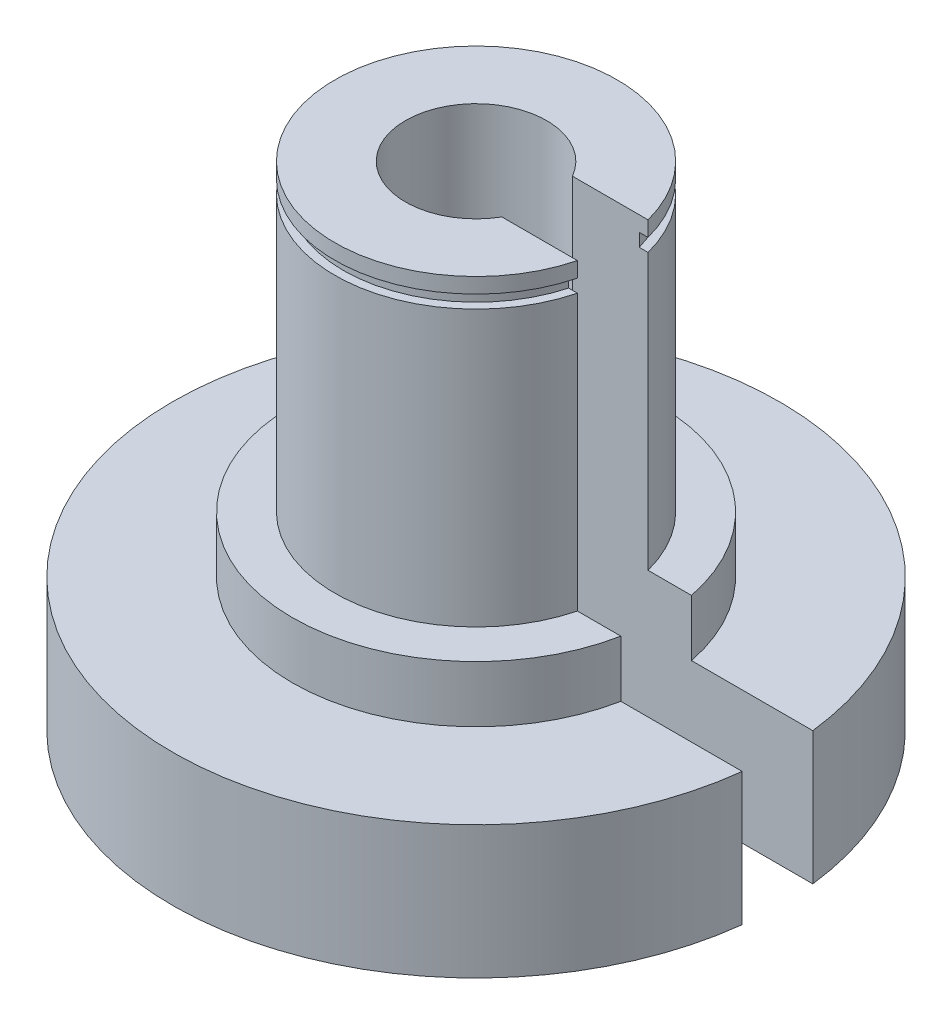
from build123d import *

# Parameters (mm, degrees)
SKETCH1_R           = 27.305
SKETCH1_R_2         = 4.5466
BOSS_EXTRUDE1_DEPTH = 57.658
SKETCH2_R           = 6.35
CUT_EXTRUDE1_DEPTH  = 44.45
SKETCH3_OUTSIDE_W   = 75.886
SKETCH3_OUTSIDE_H   = 75.886
SKETCH3_OUTSIDE_R   = 12.7
CUT_EXTRUDE2_DEPTH  = 44.45
SKETCH10_W          = 30.679481275
SKETCH10_H          = 6.35
CUT_EXTRUDE7_DEPTH  = 6.35
SKETCH13_OUTSIDE_W  = 75.886
SKETCH13_OUTSIDE_H  = 75.886
SKETCH13_OUTSIDE_R  = 11.938
CUT_EXTRUDE9_DEPTH  = 1.1684
SKETCH16_R          = 46.08237905
CUT_EXTRUDE11_DEPTH = 59.784814187
BOSS_EXTRUDE4_START = 3.81
SKETCH18_R          = 16.51
SKETCH18_R_2        = 12.7
BOSS_EXTRUDE4_DEPTH = 3.81
SKETCH19_OUTSIDE_W  = 74.42
SKETCH19_OUTSIDE_H  = 74.42
SKETCH19_OUTSIDE_R  = 16.51
CUT_EXTRUDE12_DEPTH = 1.27
SKETCH10_2_W        = 30.679481275
SKETCH10_2_H        = 6.35
CUT_EXTRUDE13_DEPTH = 59.784814187


with BuildPart() as part:
    # Sketch1 → Boss-Extrude1 (new body)
    with BuildSketch(Plane(origin=(0, 0, 0), x_dir=(1, 0, 0), z_dir=(0, 1, 0))):
        Circle(SKETCH1_R)
        Circle(SKETCH1_R_2, mode=Mode.SUBTRACT)
    extrude(amount=BOSS_EXTRUDE1_DEPTH)

    # Sketch2 → Cut-Extrude1 (cut)
    with BuildSketch(Plane(origin=(0, 57.658, 0), x_dir=(1, 0, 0), z_dir=(0, 1, 0))):
        Circle(SKETCH2_R)
    extrude(amount=-CUT_EXTRUDE1_DEPTH, mode=Mode.SUBTRACT)

    # Sketch3 outside → Cut-Extrude2 (cut)
    with BuildSketch(Plane(origin=(0, 57.658, 0), x_dir=(1, 0, 0), z_dir=(0, 1, 0))):
        Rectangle(SKETCH3_OUTSIDE_W, SKETCH3_OUTSIDE_H)
        Circle(SKETCH3_OUTSIDE_R, mode=Mode.SUBTRACT)
    extrude(amount=-CUT_EXTRUDE2_DEPTH, mode=Mode.SUBTRACT)

    # Sketch10 → Cut-Extrude7 (cut)
    with BuildSketch(Plane.XZ):
        with Locations((17.839550223, 0)):
            Rectangle(SKETCH10_W, SKETCH10_H)
    extrude(amount=-CUT_EXTRUDE7_DEPTH, mode=Mode.SUBTRACT)

    # Sketch13 outside → Cut-Extrude9 (cut)
    with BuildSketch(Plane(origin=(0, 41.783, 0), x_dir=(-1, 0, 0), z_dir=(0, 1, 0))):
        Rectangle(SKETCH13_OUTSIDE_W, SKETCH13_OUTSIDE_H)
        Circle(SKETCH13_OUTSIDE_R, mode=Mode.SUBTRACT)
    extrude(amount=CUT_EXTRUDE9_DEPTH, mode=Mode.SUBTRACT)

    # Sketch16 → Cut-Extrude11 (cut, through all)
    with BuildSketch(Plane(origin=(0, 44.323, 0), x_dir=(-1, 0, 0), z_dir=(0, 1, 0))):
        Circle(SKETCH16_R)
    extrude(amount=CUT_EXTRUDE11_DEPTH, mode=Mode.SUBTRACT)

    # Sketch18 → Boss-Extrude4 (add)
    with BuildSketch(Plane(origin=(0, 13.208, 0), x_dir=(1, 0, 0), z_dir=(0, 1, 0)).offset(BOSS_EXTRUDE4_START)):
        Circle(SKETCH18_R)
        Circle(SKETCH18_R_2, mode=Mode.SUBTRACT)
    extrude(amount=-BOSS_EXTRUDE4_DEPTH)

    # Sketch19 outside → Cut-Extrude12 (cut)
    with BuildSketch(Plane(origin=(0, 13.208, 0), x_dir=(1, 0, 0), z_dir=(0, 1, 0))):
        Rectangle(SKETCH19_OUTSIDE_W, SKETCH19_OUTSIDE_H)
        Circle(SKETCH19_OUTSIDE_R, mode=Mode.SUBTRACT)
    extrude(amount=-CUT_EXTRUDE12_DEPTH, mode=Mode.SUBTRACT)

    # Sketch10_2 → Cut-Extrude13 (cut, through all)
    with BuildSketch(Plane.XZ):
        with Locations((17.839550223, 0)):
            Rectangle(SKETCH10_2_W, SKETCH10_2_H)
    extrude(amount=-CUT_EXTRUDE13_DEPTH, mode=Mode.SUBTRACT)


solid = part.part
